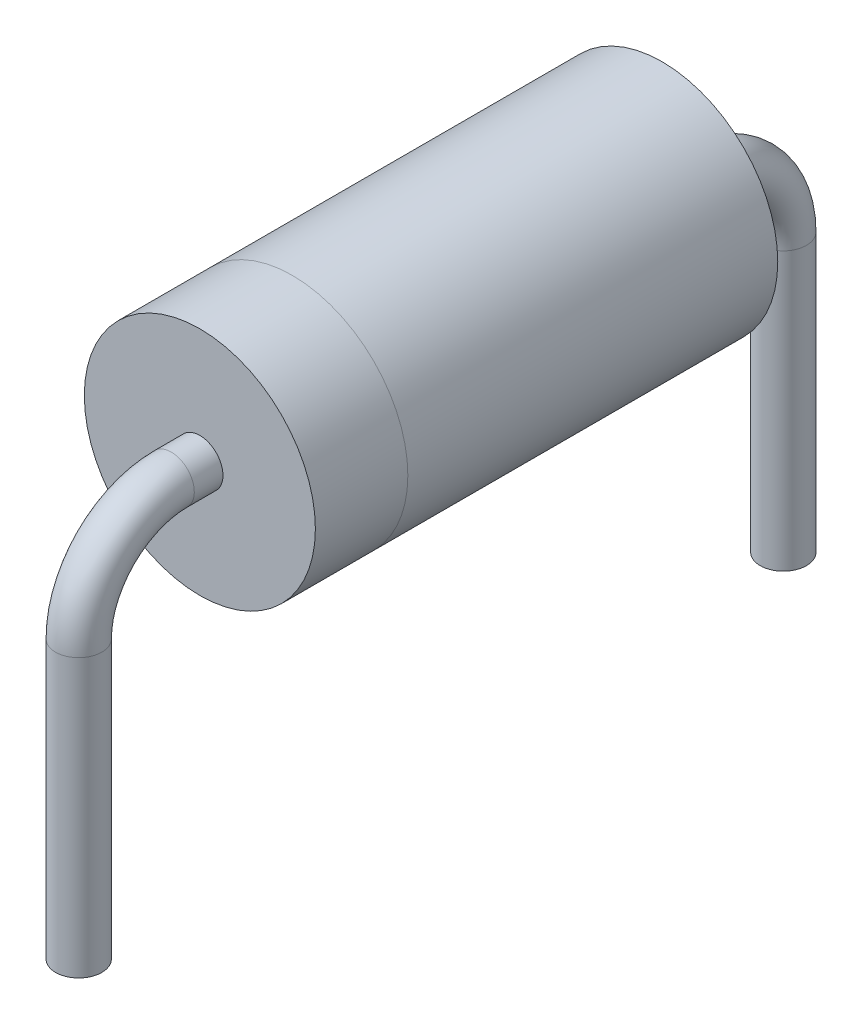
from build123d import *

# Parameters (mm, degrees)
ESQUISSE1_R        = 1.25
BOSS_EXTRU_1_DEPTH = 4
ESQUISSE2_R        = 1.2495
BOSS_EXTRU_2_DEPTH = 1
ESQUISSE4_R        = 0.25


with BuildPart() as part:
    # Esquisse1 → Boss.-Extru.1 (new body)
    with BuildSketch(Plane.XY):
        Circle(ESQUISSE1_R)
    extrude(amount=BOSS_EXTRU_1_DEPTH)

    # Esquisse2 → Boss.-Extru.2 (add)
    with BuildSketch(Plane.XY.offset(4)):
        Circle(ESQUISSE2_R)
    extrude(amount=BOSS_EXTRU_2_DEPTH)

    # Balayage1: sweep along a path in Esquisse3
    with BuildLine(Plane(origin=(0, 0, 0), x_dir=(0, 0, -1), z_dir=(1, 0, 0))) as balayage1_path:
        Line((-5, 0), (-5.31, 0))
        ThreePointArc((-5.31, 0), (-6.017106781, -0.292893219), (-6.31, -1))
        Line((-6.31, -1), (-6.31, -4))
    # Esquisse4 → Balayage1 (sweep)
    with BuildSketch(Plane.XY.offset(5)):
        Circle(ESQUISSE4_R)
    balayage1 = sweep(path=balayage1_path.line)

    # Symétrie1: Balayage1 across plane
    add(balayage1.mirror(Plane.XY.offset(2.5)))


solid = part.part
